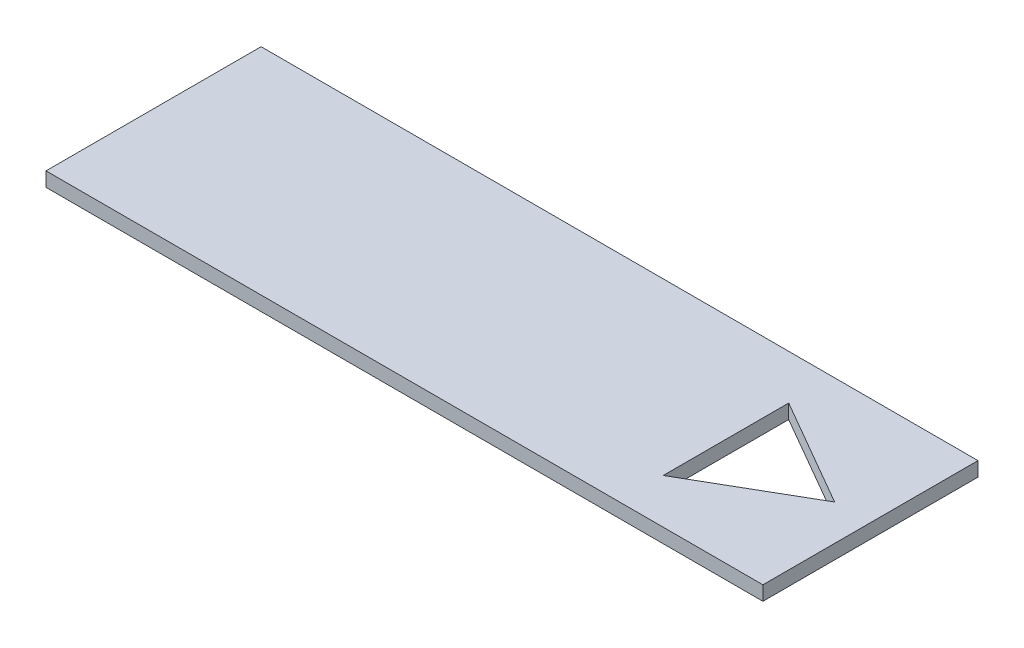
from build123d import *

# Parameters (mm, degrees)
SKETCH1_W           = 200
SKETCH1_H           = 60
BOSS_EXTRUDE1_DEPTH = 4
CUT_EXTRUDE1_DEPTH  = 5


with BuildPart() as part:
    # Sketch1 → Boss-Extrude1 (new body)
    with BuildSketch(Plane(origin=(0, 0, 0), x_dir=(1, 0, 0), z_dir=(0, 1, 0))):
        with Locations((100, 30)):
            Rectangle(SKETCH1_W, SKETCH1_H)
    extrude(amount=BOSS_EXTRUDE1_DEPTH)

    # Sketch2 → Cut-Extrude1 (cut, through all)
    with BuildSketch(Plane(origin=(0, 4, 0), x_dir=(1, 0, 0), z_dir=(0, 1, 0))):
        Polygon((190, 30), (159.689110868, 47.5), (159.689110868, 12.5), align=None)
    extrude(amount=-CUT_EXTRUDE1_DEPTH, mode=Mode.SUBTRACT)


solid = part.part
